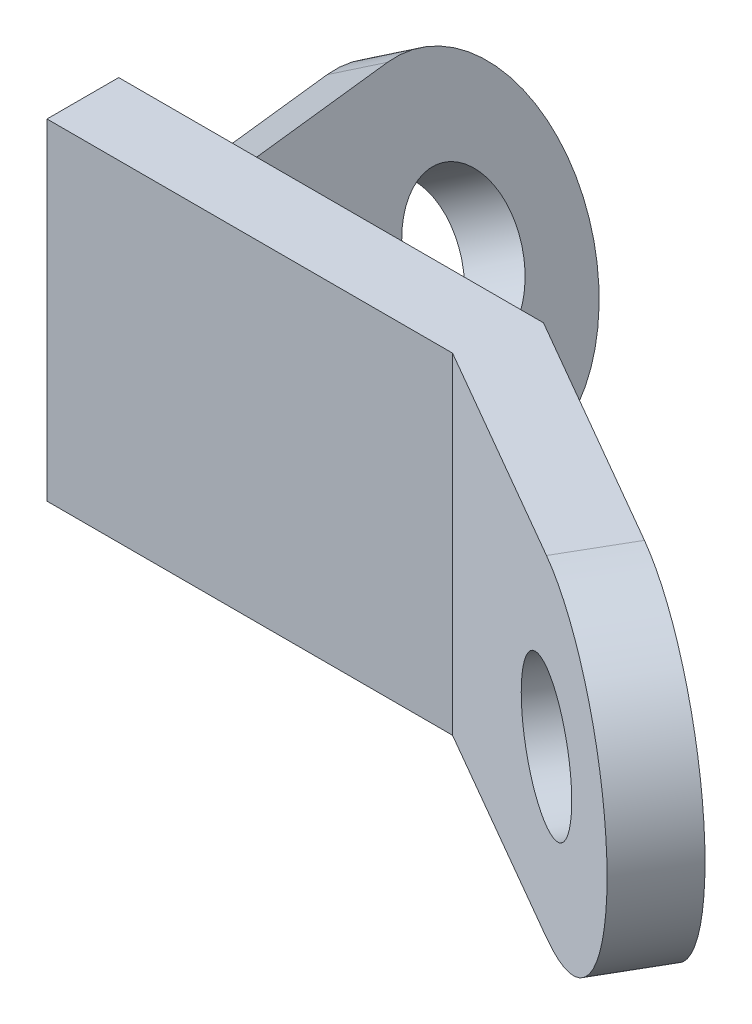
from build123d import *

# Parameters (mm, degrees)
BOSS_EXTRUDE1_DEPTH = 30
SKETCH2_R           = 12.5
CUT_EXTRUDE1_DEPTH  = 60
SKETCH4_R           = 12.5
BOSS_EXTRUDE2_DEPTH = 10


with BuildPart() as part:
    # Sketch1 → Boss-Extrude1 (new body, symmetric)
    with BuildSketch(Plane(origin=(0, 0, 0), x_dir=(1, 0, 0), z_dir=(0, 1, 0))):
        Polygon((0, -6.5), (73.516660498, -6.5), (139.782032303, -44.758330249), (146.282032303, -33.5), (77, 6.5), (0, 6.5), align=None)
    extrude(amount=BOSS_EXTRUDE1_DEPTH, both=True)

    # Sketch2 → Cut-Extrude1 (cut)
    with BuildSketch(Plane(origin=(22.064582562, 0, -38.216978046), x_dir=(-0.866025404, 0, -0.5), z_dir=(0.5, 0, -0.866025404))):
        with Locations((-113.433956091, 0)):
            Circle(SKETCH2_R)
        with BuildLine():
            Line((-143.433956091, 30), (-143.433956091, 2.09e-07))
            ThreePointArc((-143.433956091, 2.09e-07), (-134.647159453, 21.21320351), (-113.433956091, 30))
            Line((-113.433956091, 30), (-143.433956091, 30))
        make_face()
        with BuildLine():
            Line((-143.433956091, 2.09e-07), (-143.433956091, -30))
            Line((-143.433956091, -30), (-113.433956091, -30))
            ThreePointArc((-113.433956091, -30), (-134.647159601, -21.213203362), (-143.433956091, 2.09e-07))
        make_face()
    extrude(amount=-CUT_EXTRUDE1_DEPTH, mode=Mode.SUBTRACT)

    # Sketch4 → Boss-Extrude2 (add)
    with BuildSketch(Plane(origin=(31.02146997, 17.910254038, -9.598076211), x_dir=(0.5, -0.866025404, 0), z_dir=(0.836516304, 0.482962913, -0.258819045))):
        with BuildLine():
            Line((-13.480762114, -3.207364507), (41.519237886, -3.207364507))
            Line((41.519237886, -3.207364507), (41.519237886, 28.792635493))
            ThreePointArc((41.519237886, 28.792635493), (14.019237886, 56.292635493), (-13.480762114, 28.792635493))
            Line((-13.480762114, 28.792635493), (-13.480762114, -3.207364507))
        make_face()
        with Locations((14.019237886, 28.792635493)):
            Circle(SKETCH4_R, mode=Mode.SUBTRACT)
    extrude(amount=-BOSS_EXTRUDE2_DEPTH)


solid = part.part
